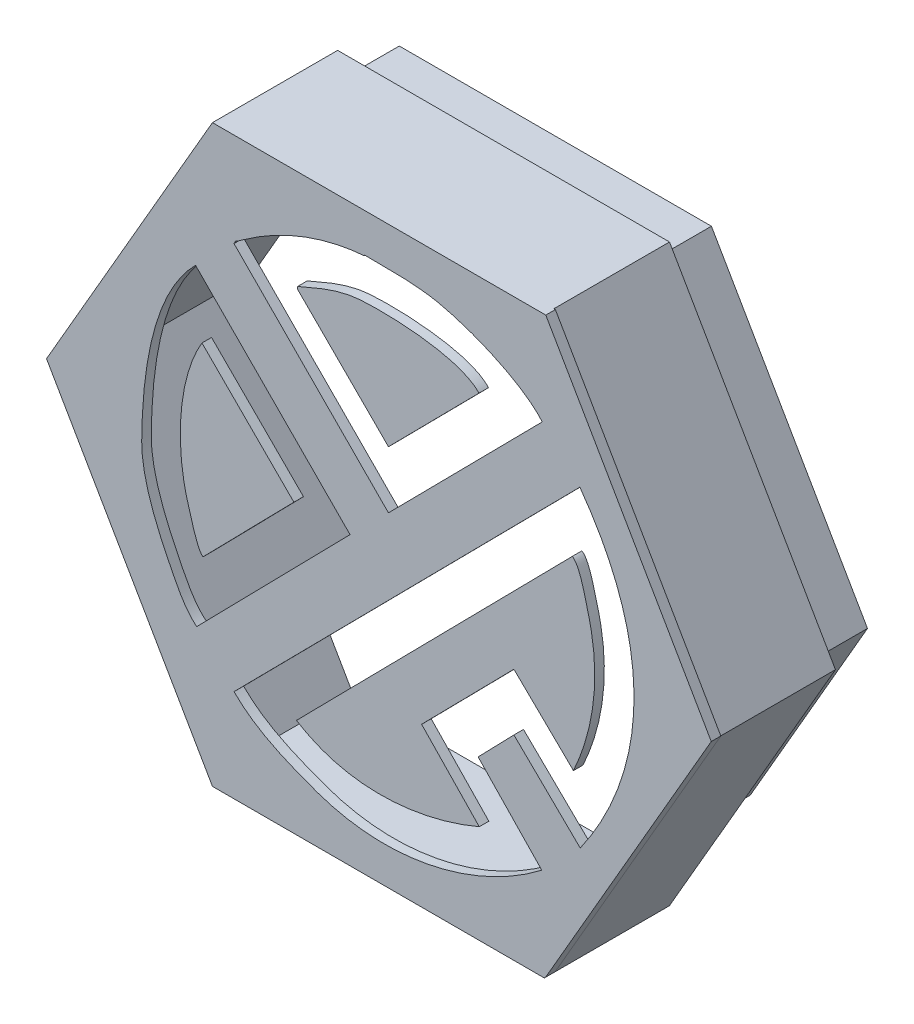
from build123d import *

# Parameters (mm, degrees)
BOSS_EXTRUDE1_DEPTH   = 25.4
BOSS_EXTRUDE1_2_DEPTH = 25.4
BOSS_EXTRUDE1_3_DEPTH = 25.4
BOSS_EXTRUDE1_4_DEPTH = 25.4
SCALE3_SCALE          = 0.05733945
BOSS_EXTRUDE2_DEPTH   = 19.05
BOSS_EXTRUDE3_DEPTH   = 25.4
SKETCH5_W             = 75.765529217
SKETCH5_H             = 7.874500512
CUT_EXTRUDE1_DEPTH    = 12.7


with BuildPart() as part:
    # Sketch1 → Boss-Extrude1 (new body)
    with BuildSketch(Plane.XY):
        Polygon((440.450276832, 1522.538105335), (1325.233417884, 1522.538105335), (1764.412204593, 761.858133149), (1324.553206335, 0), (438.587508134, 0), (0, 759.655847654), align=None)
        with BuildLine():
            Line((1315.620238534, 1272.121944702), (907.620238534, 859.121944702))
            Line((907.620238534, 859.121944702), (497.620238534, 1273.121944702))
            add(Edge.make_bspline(
                [(497.620238534, 1273.121944702), (503.17282932, 1284.227126273), (498.320802279, 1276.927235247), (513.620238534, 1288.121944702), (611.167656228, 1359.498103991), (723.220501302, 1408.359803846), (843.620238534, 1418.121944702)],
                knots=[0, 0, 0, 0, 1, 1, 1, 2, 2, 2, 2], degree=3))
            Line((843.620238534, 1418.121944702), (843.620238534, 1420.121944702))
            add(Edge.make_bspline(
                [(843.620238534, 1420.121944702), (923.5457525, 1418.832823509), (948.370291418, 1421.324065611), (1012.620238534, 1413.121944702), (1100.106609506, 1401.953471812), (1260.881011778, 1339.025444072), (1315.620238534, 1272.121944702)],
                knots=[0, 0, 0, 0, 1, 1, 1, 2, 2, 2, 2], degree=3))
        make_face(mode=Mode.SUBTRACT)
        with BuildLine():
            Line((395.620238534, 1172.121944702), (805.620238534, 758.121944702))
            Line((805.620238534, 758.121944702), (398.620238534, 343.121944702))
            add(Edge.make_bspline(
                [(398.620238534, 343.121944702), (366.769222563, 368.602757479), (344.231956123, 415.898509525), (326.620238534, 451.121944702), (290.235730332, 523.890961107), (251.977001338, 614.43082072), (252.620238534, 696.121944702), (253.82707005, 849.38954724), (277.812437988, 1054.314144156), (395.620238534, 1172.121944702)],
                knots=[0, 0, 0, 0, 1, 1, 1, 2, 2, 2, 3, 3, 3, 3], degree=3))
        make_face(mode=Mode.SUBTRACT)
        with BuildLine():
            Line((1416.620238534, 343.121944702), (1240.620238534, 515.121944702))
            Line((1240.620238534, 515.121944702), (1145.620238534, 417.121944702))
            Line((1145.620238534, 417.121944702), (1314.620238534, 241.121944702))
            add(Edge.make_bspline(
                [(1314.620238534, 241.121944702), (1147.595712269, 113.18826501), (914.836269175, 49.195471772), (710.620238534, 125.121944702), (633.853366023, 153.663474226), (556.722774397, 184.01940884), (497.620238534, 243.121944702)],
                knots=[0, 0, 0, 0, 1, 1, 1, 2, 2, 2, 2], degree=3))
            Line((497.620238534, 243.121944702), (1415.620238534, 1172.121944702))
            add(Edge.make_bspline(
                [(1415.620238534, 1172.121944702), (1612.154280964, 902.589543656), (1602.256899597, 607.138529325), (1416.620238534, 343.121944702)],
                knots=[0, 0, 0, 0, 1, 1, 1, 1], degree=3))
        make_face(mode=Mode.SUBTRACT)
    extrude(amount=BOSS_EXTRUDE1_DEPTH)


with BuildPart() as body_2:
    # Sketch1 → Boss-Extrude1 2 (new body)
    with BuildSketch(Plane.XY):
        with BuildLine():
            Line((412.620238534, 1002.121944702), (656.620238534, 758.121944702))
            Line((656.620238534, 758.121944702), (415.620238534, 512.121944702))
            add(Edge.make_bspline(
                [(415.620238534, 512.121944702), (399.555841237, 520.154143351), (381.482104958, 595.494516913), (376.620238534, 611.121944702), (340.794758453, 726.275273534), (347.589210804, 893.736898485), (412.620238534, 1002.121944702)],
                knots=[0, 0, 0, 0, 1, 1, 1, 2, 2, 2, 2], degree=3))
        make_face()
    extrude(amount=BOSS_EXTRUDE1_2_DEPTH)


with BuildPart() as body_3:
    # Sketch1 → Boss-Extrude1 3 (new body)
    with BuildSketch(Plane.XY):
        with BuildLine():
            Line((1147.620238534, 1254.121944702), (907.620238534, 1011.121944702))
            Line((907.620238534, 1011.121944702), (665.620238534, 1253.121944702))
            Line((665.620238534, 1253.121944702), (666.620238534, 1259.121944702))
            add(Edge.make_bspline(
                [(666.620238534, 1259.121944702), (714.379716252, 1279.940178579), (768.494621237, 1304.107450399), (820.620238534, 1310.121944702), (887.184884038, 1317.802480722), (1095.843990757, 1313.294799305), (1147.620238534, 1254.121944702)],
                knots=[0, 0, 0, 0, 1, 1, 1, 2, 2, 2, 2], degree=3))
        make_face()
    extrude(amount=BOSS_EXTRUDE1_3_DEPTH)


with BuildPart() as body_4:
    # Sketch1 → Boss-Extrude1 4 (new body)
    with BuildSketch(Plane.XY):
        with BuildLine():
            Line((1398.620238534, 512.121944702), (1240.620238534, 666.121944702))
            Line((1240.620238534, 666.121944702), (995.620238534, 417.121944702))
            Line((995.620238534, 417.121944702), (1148.620238534, 258.121944702))
            add(Edge.make_bspline(
                [(1148.620238534, 258.121944702), (1001.073028195, 194.887425985), (808.00065252, 168.243499438), (663.620238534, 260.121944702)],
                knots=[0, 0, 0, 0, 1, 1, 1, 1], degree=3))
            Line((663.620238534, 260.121944702), (1395.620238534, 1003.121944702))
            add(Edge.make_bspline(
                [(1395.620238534, 1003.121944702), (1416.207682281, 990.769478454), (1428.187501066, 928.879799588), (1435.620238534, 902.121944702), (1472.632527023, 768.877706144), (1455.084175852, 635.315989758), (1398.620238534, 512.121944702)],
                knots=[0, 0, 0, 0, 1, 1, 1, 2, 2, 2, 2], degree=3))
        make_face()
    extrude(amount=BOSS_EXTRUDE1_4_DEPTH)


with BuildPart() as body_4_1:
    # Scale3: scaled about (0, 0, 0)
    add(body_4.part.scale(SCALE3_SCALE))


with BuildPart() as body_2_1:
    # Scale3: scaled about (0, 0, 0)
    add(body_2.part.scale(SCALE3_SCALE))


with BuildPart() as part_1:
    # Scale3: scaled about (0, 0, 0)
    add(part.part.scale(SCALE3_SCALE))

    # Sketch3 → Boss-Extrude2 (add)
    with BuildSketch(Plane.XY.offset(1.456422017)):
        Polygon((75.765529217, -0.185000575), (101.020705623, 43.558248114), (75.765529217, 87.301496803), (25.255176406, 87.301496803), (0, 43.558248114), (25.255176406, -0.185000575), align=None)
        Polygon((98.087766255, 43.558248114), (74.299059533, 84.761496803), (26.721646089, 84.761496803), (2.932939367, 43.558248114), (26.721646089, 2.354999425), (74.299059533, 2.354999425), align=None, mode=Mode.SUBTRACT)
    extrude(amount=-BOSS_EXTRUDE2_DEPTH)

    # Sketch4 → Boss-Extrude3 (add)
    with BuildSketch(Plane.XY):
        Polygon((74.337465701, 2.481277263), (98.089719151, 43.621387033), (74.337465701, 84.761496803), (26.832958801, 84.761496803), (3.080705351, 43.621387033), (26.832958801, 2.481277263), align=None)
        Polygon((73.604230859, 3.751277263), (96.623249468, 43.621387033), (73.604230859, 83.491496803), (27.566193643, 83.491496803), (4.547175035, 43.621387033), (27.566193643, 3.751277263), align=None, mode=Mode.SUBTRACT)
    extrude(amount=-BOSS_EXTRUDE3_DEPTH)

    # Sketch5 → Cut-Extrude1 (cut)
    with BuildSketch(Plane(origin=(0, 0, 0), x_dir=(1, 0, 0), z_dir=(0, 1, 0))):
        with Locations((50.510352812, 21.503001538)):
            Rectangle(SKETCH5_W, SKETCH5_H)
    extrude(amount=CUT_EXTRUDE1_DEPTH, mode=Mode.SUBTRACT)


with BuildPart() as body_3_1:
    # Scale3: scaled about (0, 0, 0)
    add(body_3.part.scale(SCALE3_SCALE))


solid = Compound([body_4_1.part, body_2_1.part, part_1.part, body_3_1.part])
